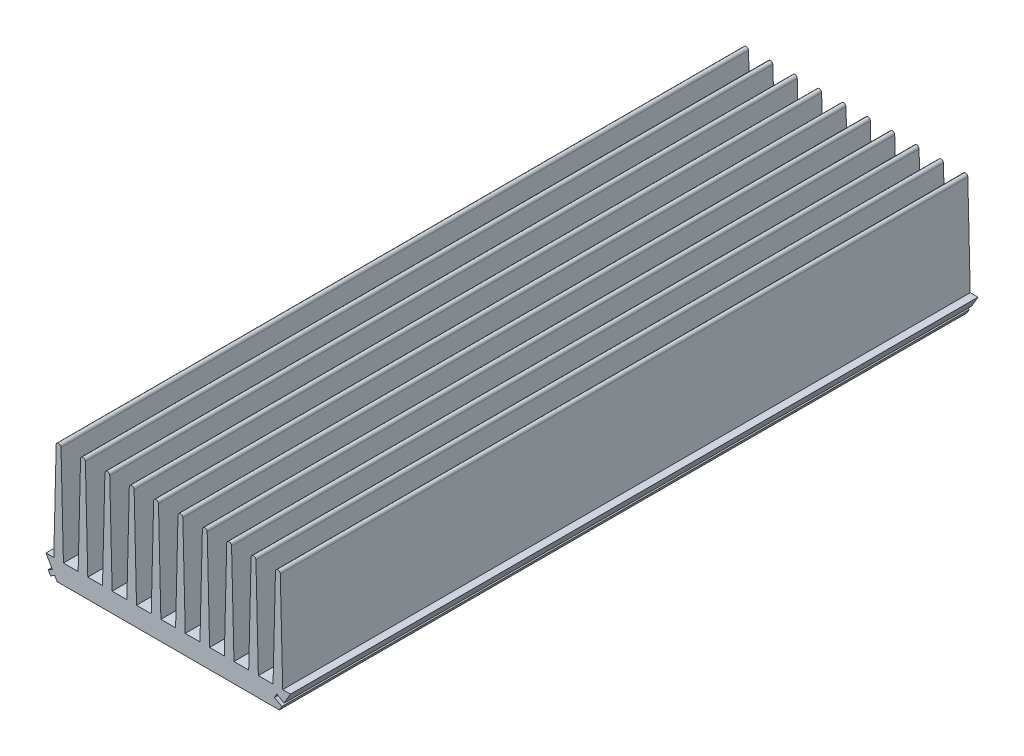
from build123d import *

# Parameters (mm, degrees)
RESSALTO_EXTRUS_O1_DEPTH   = 285
CORTE_EXTRUS_O1_DEPTH      = 1
CORTE_EXTRUS_O1_DEPTH_BACK = 286


with BuildPart() as part:
    # Esboço1 → Ressalto-extrusão1 (new body)
    with BuildSketch(Plane.XY):
        with BuildLine():
            Line((0, 0), (-115.1, 0))
            Line((-115.1, 0), (-115.1, 8))
            Line((-115.1, 8), (-114.1, 49))
            ThreePointArc((-114.1, 49), (-113.1, 50), (-112.1, 49))
            Line((-112.1, 49), (-111.1, 8))
            Line((-111.1, 8), (-105, 8))
            Line((-105, 8), (-104, 49))
            ThreePointArc((-104, 49), (-103, 50), (-102, 49))
            Line((-102, 49), (-101, 8))
            Line((-101, 8), (-94.9, 8))
            Line((-94.9, 8), (-93.9, 49))
            ThreePointArc((-93.9, 49), (-92.9, 50), (-91.9, 49))
            Line((-91.9, 49), (-90.9, 8))
            Line((-90.9, 8), (-84.8, 8))
            Line((-84.8, 8), (-83.8, 49))
            ThreePointArc((-83.8, 49), (-82.8, 50), (-81.8, 49))
            Line((-81.8, 49), (-80.8, 8))
            Line((-80.8, 8), (-74.7, 8))
            Line((-74.7, 8), (-73.7, 49))
            ThreePointArc((-73.7, 49), (-72.7, 50), (-71.7, 49))
            Line((-71.7, 49), (-70.7, 8))
            Line((-70.7, 8), (-64.6, 8))
            Line((-64.6, 8), (-63.6, 49))
            ThreePointArc((-63.6, 49), (-62.6, 50), (-61.6, 49))
            Line((-61.6, 49), (-60.6, 8))
            Line((-60.6, 8), (-54.5, 8))
            Line((-54.5, 8), (-53.5, 49))
            ThreePointArc((-53.5, 49), (-52.5, 50), (-51.5, 49))
            Line((-51.5, 49), (-50.5, 8))
            Line((-50.5, 8), (-44.4, 8))
            Line((-44.4, 8), (-43.4, 49))
            ThreePointArc((-43.4, 49), (-42.4, 50), (-41.4, 49))
            Line((-41.4, 49), (-40.4, 8))
            Line((-40.4, 8), (-34.3, 8))
            Line((-34.3, 8), (-33.3, 49))
            ThreePointArc((-33.3, 49), (-32.3, 50), (-31.3, 49))
            Line((-31.3, 49), (-30.3, 8))
            Line((-30.3, 8), (-24.2, 8))
            Line((-24.2, 8), (-23.2, 49))
            ThreePointArc((-23.2, 49), (-22.2, 50), (-21.2, 49))
            Line((-21.2, 49), (-20.2, 8))
            Line((-20.2, 8), (-14.1, 8))
            Line((-14.1, 8), (-13.1, 49))
            ThreePointArc((-13.1, 49), (-12.1, 50), (-11.1, 49))
            Line((-11.1, 49), (-10.1, 8))
            Line((-10.1, 8), (-4, 8))
            Line((-4, 8), (-3, 49))
            ThreePointArc((-3, 49), (-2, 50), (-1, 49))
            Line((-1, 49), (0, 8))
            Line((0, 8), (0, 0))
        make_face()
    extrude(amount=RESSALTO_EXTRUS_O1_DEPTH)

    # Esboço2 → Corte-extrusão1 (cut, two sides)
    with BuildSketch(Plane.XY.offset(285)) as corte_extrus_o1_sk:
        Polygon((-11.496152423, 0), (0, 0), (0, 52.247610254), (-6.877350269, 52.247610254), (-6.877350269, 8), (-9.496152423, 3.464101615), (-12.527241336, 5.214101615), (-13.527241336, 3.482050808), (-10.496152423, 1.732050808), align=None)
        Polygon((-103.603847577, 0), (-116.981639653, 0), (-116.981639653, 53.433129288), (-108.222649731, 53.433129288), (-108.222649731, 8), (-105.603847577, 3.464101615), (-107.335898385, 2.464101615), (-106.335898385, 0.732050808), (-104.603847577, 1.732050808), align=None)
    extrude(amount=CORTE_EXTRUS_O1_DEPTH, mode=Mode.SUBTRACT)
    extrude(corte_extrus_o1_sk.sketch, amount=-CORTE_EXTRUS_O1_DEPTH_BACK, mode=Mode.SUBTRACT)


solid = part.part
